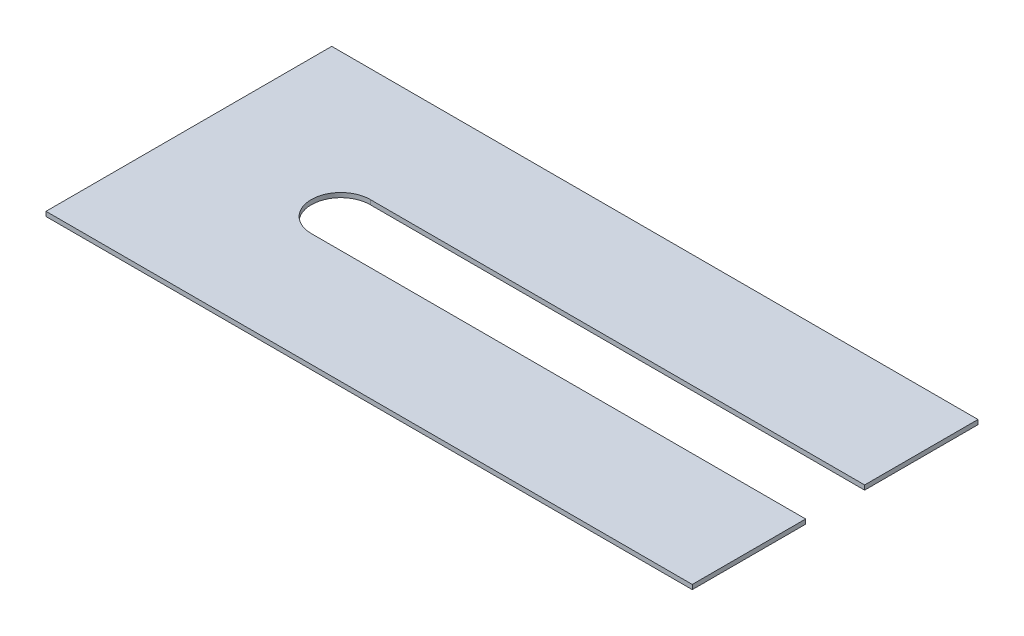
from build123d import *

# Parameters (mm, degrees)
BOSS_EXTRUDE1_DEPTH = 0.5


with BuildPart() as part:
    # Sketch1 → Boss-Extrude1 (new body)
    with BuildSketch(Plane(origin=(0, 0, 0), x_dir=(1, 0, 0), z_dir=(0, 1, 0))):
        with BuildLine():
            Line((0, 31.5), (0, 0))
            Line((0, 0), (71.25, 0))
            Line((71.25, 0), (71.25, 12.5))
            Line((71.25, 12.5), (16.75, 12.5))
            ThreePointArc((16.75, 12.5), (13.5, 15.75), (16.75, 19))
            Line((16.75, 19), (71.25, 19))
            Line((71.25, 19), (71.25, 31.5))
            Line((71.25, 31.5), (0, 31.5))
        make_face()
    extrude(amount=BOSS_EXTRUDE1_DEPTH)


solid = part.part
